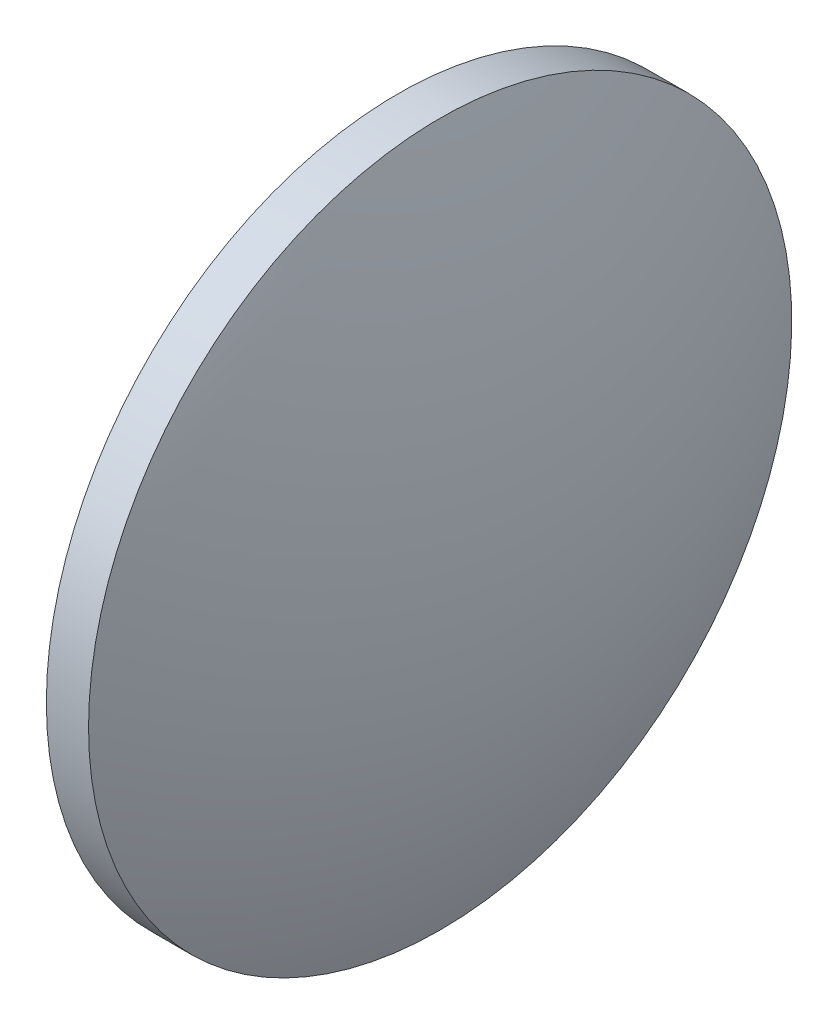
from build123d import *


with BuildPart() as part:
    # 草图1 → 旋转1 (revolve)
    with BuildSketch(Plane.XY, mode=Mode.PRIVATE) as revolve_1_sk:
        with BuildLine():
            Line((590.757854946, 196.702283009), (590.757854946, 209.202283009))
            Line((590.757854946, 209.202283009), (592.257854946, 209.202283009))
            ThreePointArc((592.257854946, 209.202283009), (594.126726906, 203.076057401), (594.757854946, 196.702283009))
            Line((594.757854946, 196.702283009), (590.757854946, 196.702283009))
        make_face()
    revolve(revolve_1_sk.sketch.rotate(Axis((588.392239043, 196.702283009, 0), (1, 0, 0)), 180), axis=Axis((588.392239043, 196.702283009, 0), (1, 0, 0)))  # turned: the seam where the file's is


solid = part.part
